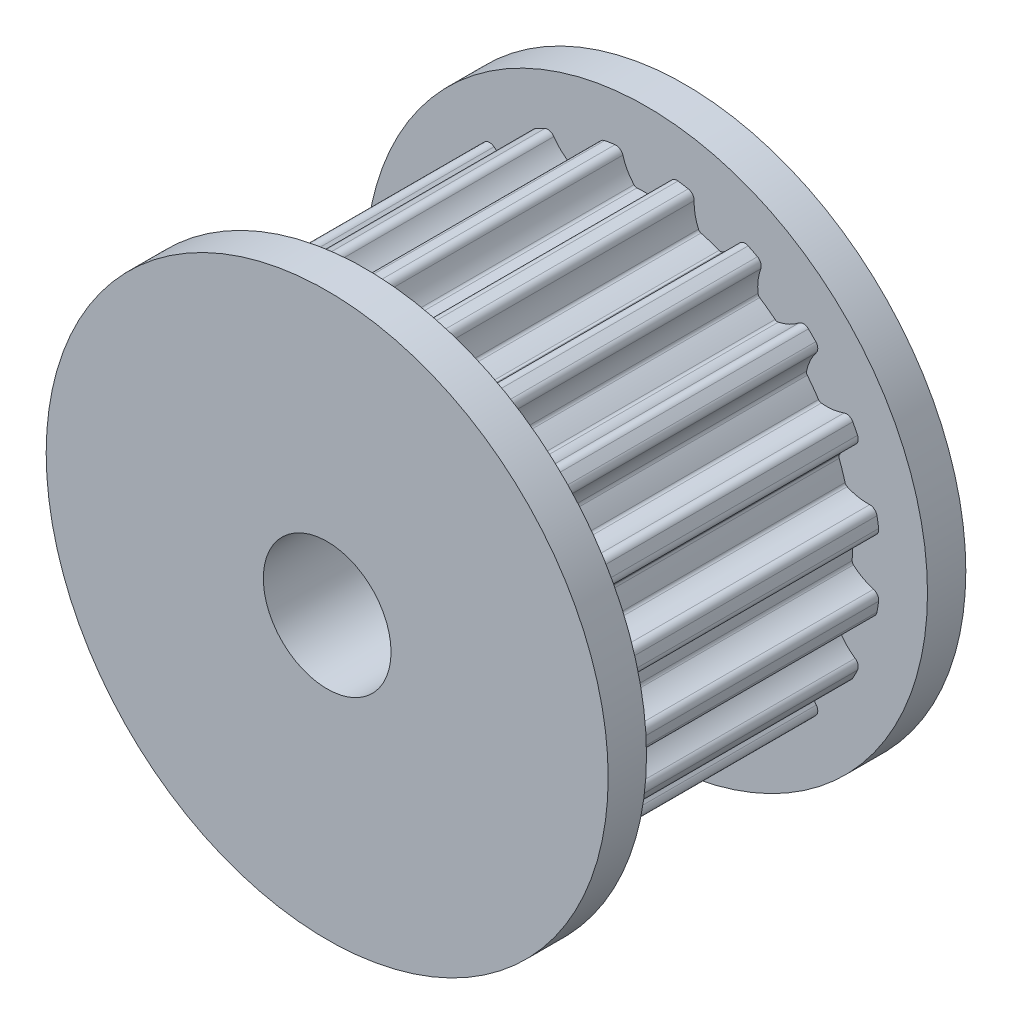
from build123d import *

# Parameters (mm, degrees)
SKETCH_1_R               = 9.17
EXTRUDE_1_DEPTH          = 5.5
CUT_EXTRUDE_START        = -12
CUT_EXTRUDE_1_DEPTH      = 13
PATTERN_CIRCULAR_1_COUNT = 20
SKETCH_3_R               = 11
EXTRUDE_2_DEPTH          = 1.5
SKETCH_9_R               = 11
EXTRUDE_3_DEPTH          = 1.5
SKETCH_4_R               = 2.5
CUT_EXTRUDE_2_DEPTH      = 15
SKETCH_10_R              = 2
CUT_EXTRUDE_3_DEPTH      = 12
SKETCH_11_R              = 2
CUT_EXTRUDE_4_DEPTH      = 12


with BuildPart() as part:
    # 草圖1 → 填料-伸長1 (new body, symmetric)
    with BuildSketch(Plane.XY):
        Circle(SKETCH_1_R)
    extrude(amount=EXTRUDE_1_DEPTH, both=True)

    # 草圖2 → 除料-伸長1 (cut)
    with BuildSketch(Plane.XY.offset(5.5).offset(CUT_EXTRUDE_START)):
        with BuildLine():
            ThreePointArc((-0.372835703, 8.051372153), (0, 8.06), (0.372835703, 8.051372153))
            ThreePointArc((0.372835703, 8.051372153), (0.437515299, 8.062770331), (0.491125647, 8.100708427))
            ThreePointArc((0.491125647, 8.100708427), (0.753329245, 8.468226481), (0.925222062, 8.885686787))
            ThreePointArc((0.925222062, 8.885686787), (1.041179318, 9.043582036), (1.232246479, 9.086829404))
            ThreePointArc((1.232246479, 9.086829404), (0, 9.17), (-1.232246479, 9.086829404))
            ThreePointArc((-1.232246479, 9.086829404), (-1.041179318, 9.043582036), (-0.925222062, 8.885686787))
            ThreePointArc((-0.925222062, 8.885686787), (-0.753329245, 8.468226481), (-0.491125647, 8.100708427))
            ThreePointArc((-0.491125647, 8.100708427), (-0.437515299, 8.062770331), (-0.372835703, 8.051372153))
        make_face()
    cut_extrude_1 = extrude(amount=CUT_EXTRUDE_1_DEPTH, mode=Mode.SUBTRACT)

    # 環狀複製排列1: 除料-伸長1 ×20 about axis
    pattern_circular_1_axis = Axis((0, 0, 0), (0, 0, 1))
    for i in range(1, PATTERN_CIRCULAR_1_COUNT):
        add(cut_extrude_1.rotate(pattern_circular_1_axis, i * 360 / PATTERN_CIRCULAR_1_COUNT), mode=Mode.SUBTRACT)

    # 草圖3 → 填料-伸長2 (add)
    with BuildSketch(Plane.XY.offset(5.5)):
        Circle(SKETCH_3_R)
    extrude(amount=EXTRUDE_2_DEPTH)

    # 草圖9 → 填料-伸長3 (add)
    with BuildSketch(Plane(origin=(0, 0, -5.5), x_dir=(-1, 0, 0), z_dir=(0, 0, -1))):
        Circle(SKETCH_9_R)
    extrude(amount=EXTRUDE_3_DEPTH)

    # 草圖4 → 除料-伸長2 (cut, through all)
    with BuildSketch(Plane.XY.offset(7)):
        Circle(SKETCH_4_R)
    extrude(amount=-CUT_EXTRUDE_2_DEPTH, mode=Mode.SUBTRACT)

    # 草圖10 → 除料-伸長3 (cut, through all)
    with BuildSketch(Plane(origin=(0, 0, 0), x_dir=(1, 0, 0), z_dir=(0, 1, 0))):
        Circle(SKETCH_10_R)
    extrude(amount=-CUT_EXTRUDE_3_DEPTH, mode=Mode.SUBTRACT)

    # 草圖11 → 除料-伸長4 (cut, through all)
    with BuildSketch(Plane(origin=(0, 0, 0), x_dir=(0, 0, -1), z_dir=(1, 0, 0))):
        Circle(SKETCH_11_R)
    extrude(amount=-CUT_EXTRUDE_4_DEPTH, mode=Mode.SUBTRACT)


solid = part.part
